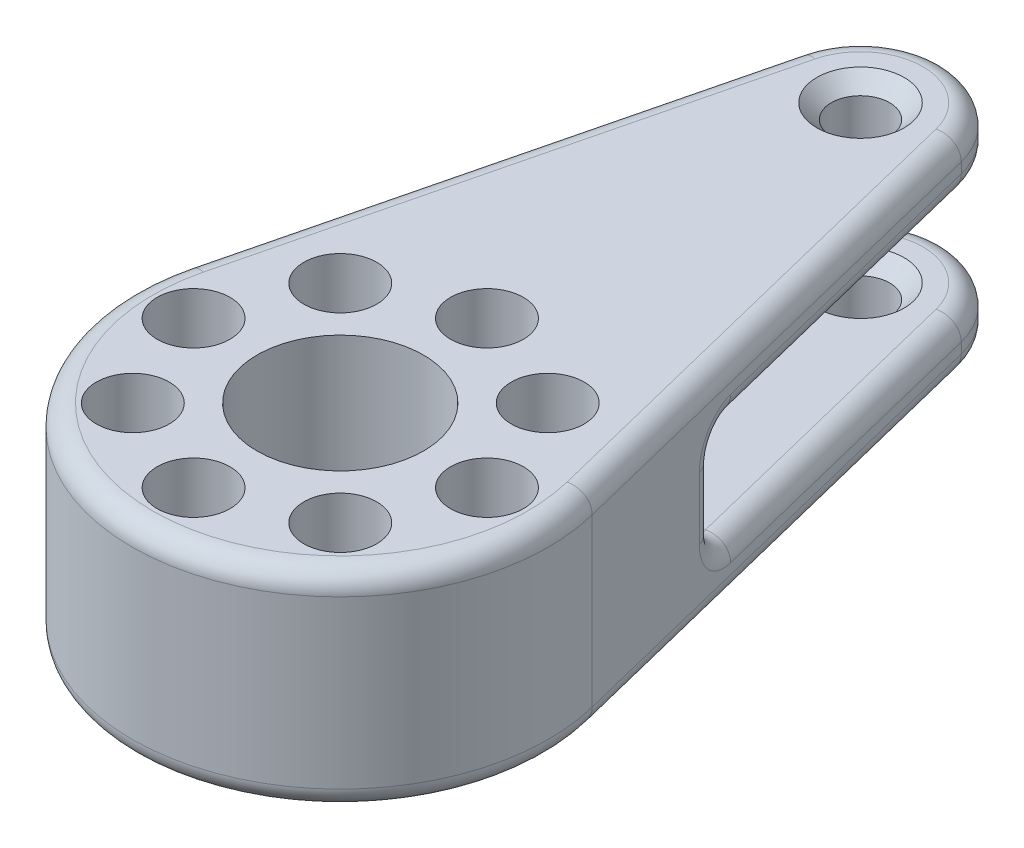
from build123d import *

# Parameters (mm, degrees)
SKETCH1_R           = 1.4
SKETCH1_R_2         = 4
BOSS_EXTRUDE1_DEPTH = 5
SKETCH2_R           = 0.75
CUT_EXTRUDE1_DEPTH  = 6
CUT_EXTRUDE2_START  = -4
SKETCH4_R           = 1.75
CUT_EXTRUDE2_DEPTH  = 10
CIRPATTERN1_COUNT   = 8
CUT_EXTRUDE3_DEPTH  = 2.5
FILLET1_R           = 1
CHAMFER1_SIZE       = 0.7


with BuildPart() as part:
    # Sketch1 → Boss-Extrude1 (new body, symmetric)
    with BuildSketch(Plane(origin=(0, 0, 0), x_dir=(1, 0, 0), z_dir=(0, 1, 0))):
        with BuildLine():
            Line((-9.70772888, 2.4), (-3.883091552, 25.96))
            ThreePointArc((-3.883091552, 25.96), (0, 29), (3.883091552, 25.96))
            Line((3.883091552, 25.96), (9.70772888, 2.4))
            ThreePointArc((9.70772888, 2.4), (0, -10), (-9.70772888, 2.4))
        make_face()
        with Locations((0, 25)):
            Circle(SKETCH1_R, mode=Mode.SUBTRACT)
        Circle(SKETCH1_R_2, mode=Mode.SUBTRACT)
    extrude(amount=BOSS_EXTRUDE1_DEPTH, both=True)

    # Sketch2 → Cut-Extrude1 (cut, symmetric)
    with BuildSketch(Plane(origin=(0, 0, 0), x_dir=(1, 0, 0), z_dir=(0, 1, 0))):
        with Locations((0, 7.05)):
            Circle(SKETCH2_R)
    cut_extrude1 = extrude(amount=CUT_EXTRUDE1_DEPTH, both=True, mode=Mode.SUBTRACT)

    # Sketch4 → Cut-Extrude2 (cut)
    with BuildSketch(Plane(origin=(0, 0, 0), x_dir=(1, 0, 0), z_dir=(0, 1, 0)).offset(CUT_EXTRUDE2_START)):
        with Locations((0, 7.05)):
            Circle(SKETCH4_R)
    cut_extrude2 = extrude(amount=CUT_EXTRUDE2_DEPTH, mode=Mode.SUBTRACT)

    # CirPattern1: Cut-Extrude1, Cut-Extrude2 ×8 about axis
    cirpattern1_axis = Axis((0, 0, 0), (0, 1, 0))
    for i in range(1, CIRPATTERN1_COUNT):
        add(cut_extrude1.rotate(cirpattern1_axis, i * 360 / CIRPATTERN1_COUNT), mode=Mode.SUBTRACT)
        add(cut_extrude2.rotate(cirpattern1_axis, i * 360 / CIRPATTERN1_COUNT), mode=Mode.SUBTRACT)

    # Sketch5 → Cut-Extrude3 (cut, symmetric)
    with BuildSketch(Plane(origin=(0, 0, 0), x_dir=(1, 0, 0), z_dir=(0, 1, 0))):
        with BuildLine():
            Line((-7.828813613, 10), (7.828813613, 10))
            Line((7.828813613, 10), (3.883091552, 25.96))
            ThreePointArc((3.883091552, 25.96), (0, 29), (-3.883091552, 25.96))
            Line((-3.883091552, 25.96), (-7.828813613, 10))
        make_face()
    extrude(amount=CUT_EXTRUDE3_DEPTH, both=True, mode=Mode.SUBTRACT)

    # Fillet1
    fillet1_edges = [part.edges().sort_by_distance(p)[0] for p in [
        (0, 2.5, -10),
        (5.855952582, 2.5, -17.98),
        (0, 2.5, -29),
        (6.795410216, 5, -14.18),
        (0, 5, -29),
        (-6.795410216, 5, -14.18),
        (0, 5, 10),
        (0, -5, 10),
        (-6.795410216, -5, -14.18),
        (0, -5, -29),
        (6.795410216, -5, -14.18),
        (-5.855952582, -2.5, -17.98),
        (0, -2.5, -10),
        (-7.828813613, 0, -10),
        (5.855952582, -2.5, -17.98),
        (7.828813613, 0, -10),
        (0, -2.5, -29),
        (-5.855952582, 2.5, -17.98),
    ]]
    fillet(fillet1_edges, radius=FILLET1_R)

    # Chamfer1
    chamfer1_edges = [part.edges().sort_by_distance(p)[0] for p in [
        (-1.4, -2.5, -25),
        (-1.4, 5, -25),
    ]]
    chamfer(chamfer1_edges, length=CHAMFER1_SIZE)


solid = part.part
